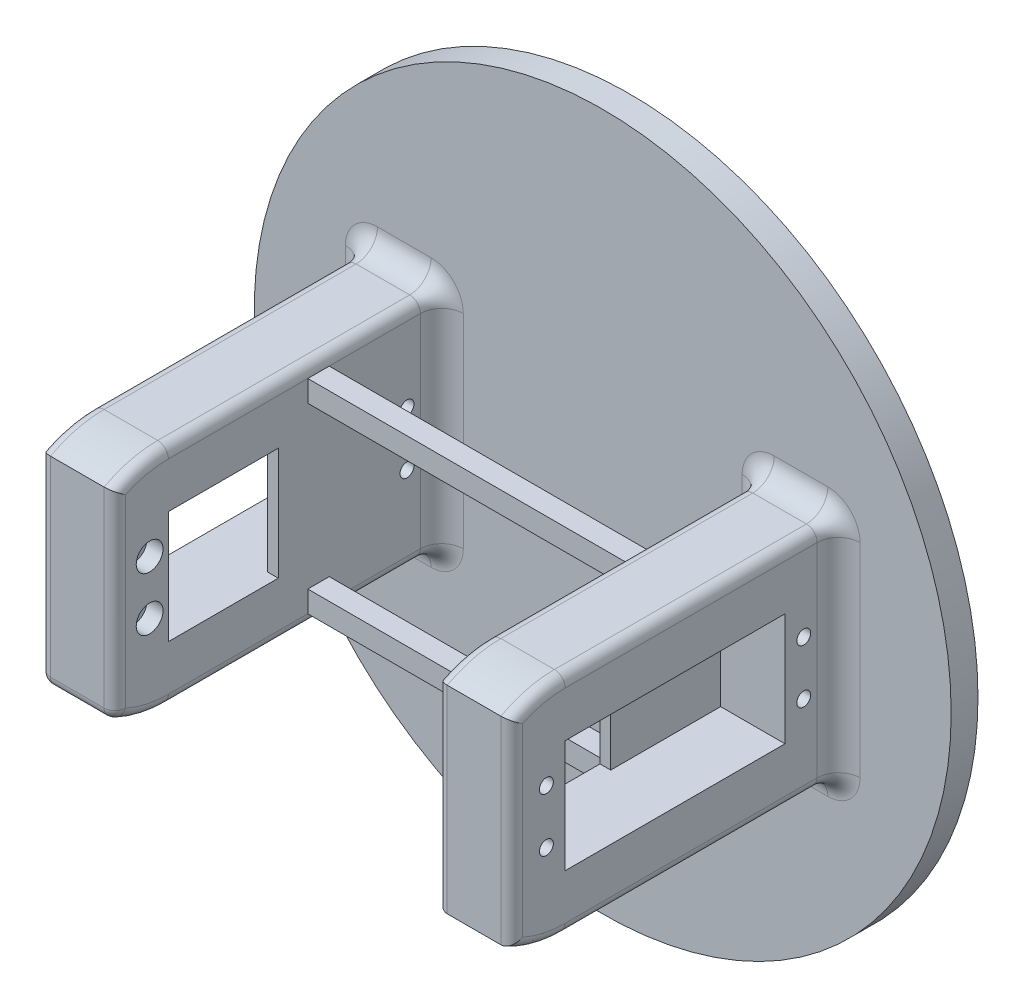
from build123d import *

# Parameters (mm, degrees)
SKETCH1_R           = 65
BOSS_EXTRUDE1_DEPTH = 5
SKETCH2_W           = 14
SKETCH2_H           = 70
BOSS_EXTRUDE2_DEPTH = 70
SKETCH4_W           = 41
SKETCH4_H           = 21
CUT_EXTRUDE1_DEPTH  = 12
CUT_EXTRUDE2_DEPTH  = 14
FILLET1_R           = 2
FILLET2_R           = 4
FILLET3_R           = 2
FILLET4_R           = 4
SKETCH7_R           = 1.3
CUT_EXTRUDE3_DEPTH  = 14
SKETCH8_W           = 20.5
SKETCH8_H           = 21
CUT_EXTRUDE4_DEPTH  = 2
SKETCH9_W           = 60
SKETCH9_H           = 4
BOSS_EXTRUDE3_DEPTH = 4
SKETCH10_R          = 2.5
SKETCH10_R_2        = 1.3
CUT_EXTRUDE5_DEPTH  = 3


with BuildPart() as part:
    # Sketch1 → Boss-Extrude1 (new body)
    with BuildSketch(Plane.XY):
        Circle(SKETCH1_R)
    extrude(amount=BOSS_EXTRUDE1_DEPTH)

    # Sketch2 → Boss-Extrude2 (add)
    with BuildSketch(Plane.XY.offset(5)):
        with Locations((-37, 0)):
            Rectangle(SKETCH2_W, SKETCH2_H)
        with Locations((37, 0)):
            Rectangle(SKETCH2_W, SKETCH2_H)
    extrude(amount=BOSS_EXTRUDE2_DEPTH)

    # Sketch4 → Cut-Extrude1 (cut)
    with BuildSketch(Plane.ZY.offset(44)):
        with Locations((35.5, 0)):
            Rectangle(SKETCH4_W, SKETCH4_H)
    cut_extrude1 = extrude(amount=-CUT_EXTRUDE1_DEPTH, mode=Mode.SUBTRACT)

    # Sketch5 → Cut-Extrude2 (cut)
    with BuildSketch(Plane.ZY.offset(44)):
        with BuildLine():
            Line((56, -21), (5, -21))
            Line((5, -21), (5, -35))
            Line((5, -35), (75, -35))
            Line((75, -35), (75, -8.94427191))
            ThreePointArc((75, -8.94427191), (71.261608982, -14.425092419), (66, -18.466185313))
            ThreePointArc((66, -18.466185313), (61.158008745, -20.356692899), (56, -21))
        make_face()
        with BuildLine():
            Line((5, 35), (5, 21))
            Line((5, 21), (56, 21))
            ThreePointArc((56, 21), (61.158008745, 20.356692899), (66, 18.466185313))
            ThreePointArc((66, 18.466185313), (71.261608982, 14.425092419), (75, 8.94427191))
            Line((75, 8.94427191), (75, 35))
            Line((75, 35), (5, 35))
        make_face()
        with BuildLine():
            ThreePointArc((75, 8.94427191), (71.261608982, 14.425092419), (66, 18.466185313))
            Line((66, 18.466185313), (66, -18.466185313))
            ThreePointArc((66, -18.466185313), (71.261608982, -14.425092419), (75, -8.94427191))
            Line((75, -8.94427191), (75, 8.94427191))
        make_face()
    cut_extrude2 = extrude(amount=-CUT_EXTRUDE2_DEPTH, mode=Mode.SUBTRACT)

    # Fillet1
    fillet1_edges = [part.edges().sort_by_distance(p)[0] for p in [
        (-30, -20.356692899, 61.158008745),
        (-44, -20.356692899, 61.158008745),
        (-37, -18.466185313, 66),
        (-30, 20.356692899, 61.158008745),
        (-44, 20.356692899, 61.158008745),
        (-30, -21, 30.5),
        (-44, -21, 30.5),
        (-44, 21, 30.5),
        (-44, 0, 66),
        (-30, 21, 30.5),
        (-30, 0, 66),
    ]]
    fillet(fillet1_edges, radius=FILLET1_R)

    # Fillet2
    fillet2_edges = [part.edges().sort_by_distance(p)[0] for p in [
        (-30, 0, 5),
        (-44, 0, 5),
        (-37, 21, 5),
        (-37, -21, 5),
        (-43.414213562, 20.414213562, 5),
        (-30.585786438, 20.414213562, 5),
        (-30.585786438, -20.414213562, 5),
        (-43.414213562, -20.414213562, 5),
    ]]
    fillet(fillet2_edges, radius=FILLET2_R)

    # Mirror2: Cut-Extrude1 across plane
    add(cut_extrude1.mirror(Plane(origin=(0, 0, 0), x_dir=(0, 0, 1), z_dir=(1, 0, 0))), mode=Mode.SUBTRACT)

    # Mirror3: Cut-Extrude2 across plane
    add(cut_extrude2.mirror(Plane(origin=(0, 0, 0), x_dir=(0, 0, 1), z_dir=(1, 0, 0))), mode=Mode.SUBTRACT)

    # Fillet3
    fillet3_edges = [part.edges().sort_by_distance(p)[0] for p in [
        (44, -20.356692899, 61.158008745),
        (44, 20.356692899, 61.158008745),
        (44, -21, 30.5),
        (30, 0, 66),
        (44, 0, 66),
        (30, 21, 30.5),
        (44, 21, 30.5),
        (30, -20.356692899, 61.158008745),
        (30, -21, 30.5),
        (30, 20.356692899, 61.158008745),
    ]]
    fillet(fillet3_edges, radius=FILLET3_R)

    # Fillet4
    fillet4_edges = [part.edges().sort_by_distance(p)[0] for p in [
        (30, 0, 5),
        (44, 0, 5),
        (37, 21, 5),
        (37, -21, 5),
        (30.585786438, 20.414213562, 5),
        (30.585786438, -20.414213562, 5),
        (43.414213562, 20.414213562, 5),
        (43.414213562, -20.414213562, 5),
    ]]
    fillet(fillet4_edges, radius=FILLET4_R)

    # Sketch7 → Cut-Extrude3 (cut)
    with BuildSketch(Plane.ZY.offset(44)):
        with Locations((59.5, 5)):
            Circle(SKETCH7_R)
        with Locations((59.5, -5)):
            Circle(SKETCH7_R)
        with Locations((11.5, -5)):
            Circle(SKETCH7_R)
        with Locations((11.5, 5)):
            Circle(SKETCH7_R)
    cut_extrude3 = extrude(amount=-CUT_EXTRUDE3_DEPTH, mode=Mode.SUBTRACT)

    # Mirror6: Cut-Extrude3 across plane
    add(cut_extrude3.mirror(Plane(origin=(0, 0, 0), x_dir=(0, 0, 1), z_dir=(1, 0, 0))), mode=Mode.SUBTRACT)

    # Sketch8 → Cut-Extrude4 (cut)
    with BuildSketch(Plane.ZY.offset(32)):
        with Locations((45.75, 0)):
            Rectangle(SKETCH8_W, SKETCH8_H)
    cut_extrude4 = extrude(amount=-CUT_EXTRUDE4_DEPTH, mode=Mode.SUBTRACT)

    # Mirror7: Cut-Extrude4 across plane
    add(cut_extrude4.mirror(Plane(origin=(0, 0, 0), x_dir=(0, 0, 1), z_dir=(1, 0, 0))), mode=Mode.SUBTRACT)

    # Sketch9 → Boss-Extrude3 (add)
    with BuildSketch(Plane.XY.offset(30)):
        with Locations((0, -17)):
            Rectangle(SKETCH9_W, SKETCH9_H)
    boss_extrude3 = extrude(amount=-BOSS_EXTRUDE3_DEPTH)

    # Mirror8: Boss-Extrude3 across plane
    add(boss_extrude3.mirror(Plane.ZX))

    # Sketch10 → Cut-Extrude5 (cut)
    with BuildSketch(Plane(origin=(-30, 0, 0), x_dir=(0, 0, -1), z_dir=(1, 0, 0))):
        with Locations((-59.5, 5)):
            Circle(SKETCH10_R)
        with Locations((-59.5, 5)):
            Circle(SKETCH10_R_2, mode=Mode.SUBTRACT)
        with Locations((-59.5, -5)):
            Circle(SKETCH10_R)
        with Locations((-59.5, -5)):
            Circle(SKETCH10_R_2, mode=Mode.SUBTRACT)
    cut_extrude5 = extrude(amount=-CUT_EXTRUDE5_DEPTH, mode=Mode.SUBTRACT)

    # Mirror9: Cut-Extrude5 across plane
    add(cut_extrude5.mirror(Plane(origin=(0, 0, 0), x_dir=(0, 0, 1), z_dir=(1, 0, 0))), mode=Mode.SUBTRACT)


solid = part.part
